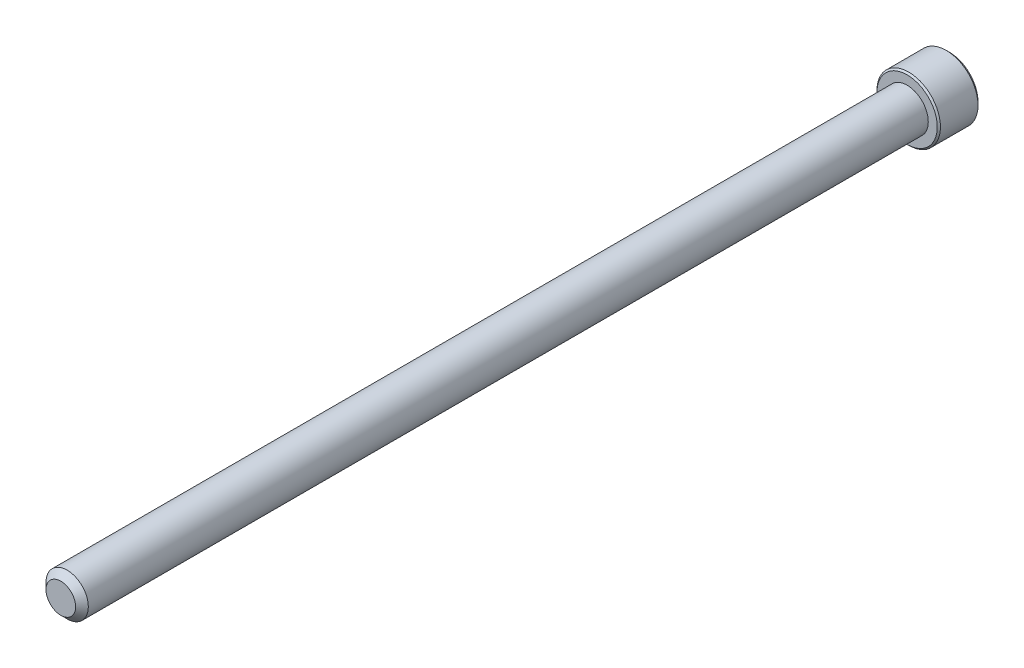
from build123d import *

# Parameters (mm, degrees)
SKETCH1_R          = 3.175
EXTRUDE1_DEPTH     = 127
CHAMFER3_SIZE      = 0.9525
SKETCH6_R          = 4.7625
EXTRUDE2_DEPTH     = 6.35
CUT_EXTRUDE1_DEPTH = 3.571875
CHAMFER1_SIZE      = 0.47625
CHAMFER2_SIZE      = 0.238125


with BuildPart() as part:
    # Sketch1 → Extrude1 (new body)
    with BuildSketch(Plane.XY):
        Circle(SKETCH1_R)
    extrude(amount=-EXTRUDE1_DEPTH)

    # Chamfer3
    chamfer3_edges = [part.edges().sort_by_distance(p)[0] for p in [
        (-3.175, 0, 0),
    ]]
    chamfer(chamfer3_edges, length=CHAMFER3_SIZE)

    # Sketch6 → Extrude2 (add)
    with BuildSketch(Plane(origin=(0, 0, -127), x_dir=(-1, 0, 0), z_dir=(0, 0, -1))):
        Circle(SKETCH6_R)
    extrude(amount=EXTRUDE2_DEPTH)

    # Sketch7 → Cut-Extrude1 (cut)
    with BuildSketch(Plane(origin=(0, 0, -133.35), x_dir=(-1, 0, 0), z_dir=(0, 0, -1))):
        Polygon((0, 2.749630657), (-2.38125, 1.374815329), (-2.38125, -1.374815329), (0, -2.749630657), (2.38125, -1.374815329), (2.38125, 1.374815329), align=None)
    extrude(amount=-CUT_EXTRUDE1_DEPTH, mode=Mode.SUBTRACT)

    # Cut-Extrude2 cone 1 section (through the dimple's axis) → Cut-Extrude2 (revolve, cut)
    with BuildSketch(Plane(origin=(0, 0, -133.35), x_dir=(0, 1, 0), z_dir=(1, 0, 0))):
        Polygon((0, 0), (2.749630657, 0), (0, 2.749630657), align=None)
    revolve(axis=Axis((0, 0, -133.35), (0, 0, 1)), mode=Mode.SUBTRACT)

    # Chamfer1
    chamfer1_edges = [part.edges().sort_by_distance(p)[0] for p in [
        (4.7625, 0, -133.35),
    ]]
    chamfer(chamfer1_edges, length=CHAMFER1_SIZE)

    # Chamfer2
    chamfer2_edges = [part.edges().sort_by_distance(p)[0] for p in [
        (4.7625, 0, -127),
    ]]
    chamfer(chamfer2_edges, length=CHAMFER2_SIZE)


solid = part.part
